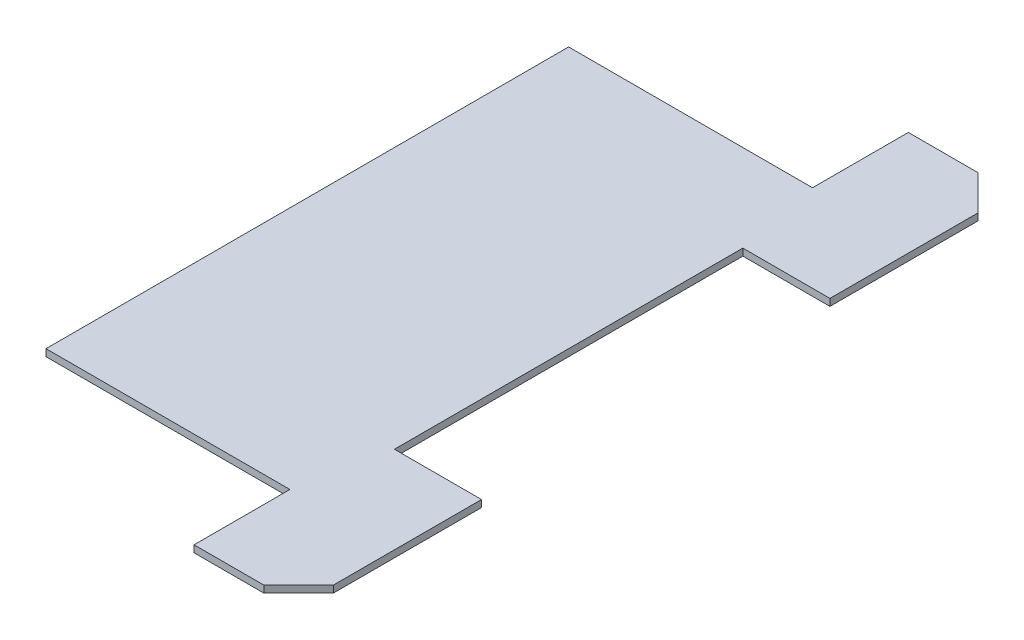
from build123d import *

# Parameters (mm, degrees)
EXTRUDE_1_DEPTH = 0.2


with BuildPart() as part:
    # Эскиз1 → Бобышка-Вытянуть1 (new body)
    with BuildSketch(Plane(origin=(0, 0, 0), x_dir=(1, 0, 0), z_dir=(0, 1, 0))):
        Polygon((5, -9.25), (5, -5), (2.5, -5), (2.5, 5), (5, 5), (5, 9.25), (4, 10.25), (2, 10.25), (2, 7.5), (-5, 7.5), (-5, -7.5), (2, -7.5), (2, -10.25), (4, -10.25), align=None)
    extrude(amount=EXTRUDE_1_DEPTH)


solid = part.part
